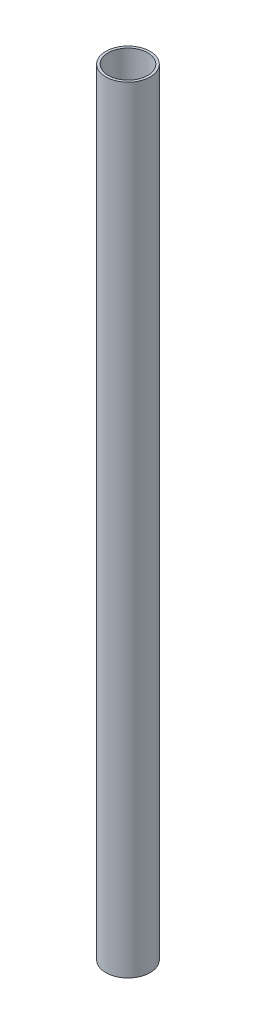
from build123d import *

# Parameters (mm, degrees)
CROQUIS1_R              = 9
CROQUIS1_R_2            = 8
SALIENTE_EXTRUIR1_DEPTH = 315


with BuildPart() as part:
    # Croquis1 → Saliente-Extruir1 (new body)
    with BuildSketch(Plane(origin=(0, 0, 0), x_dir=(1, 0, 0), z_dir=(0, 1, 0))):
        Circle(CROQUIS1_R)
        Circle(CROQUIS1_R_2, mode=Mode.SUBTRACT)
    extrude(amount=SALIENTE_EXTRUIR1_DEPTH)


solid = part.part
